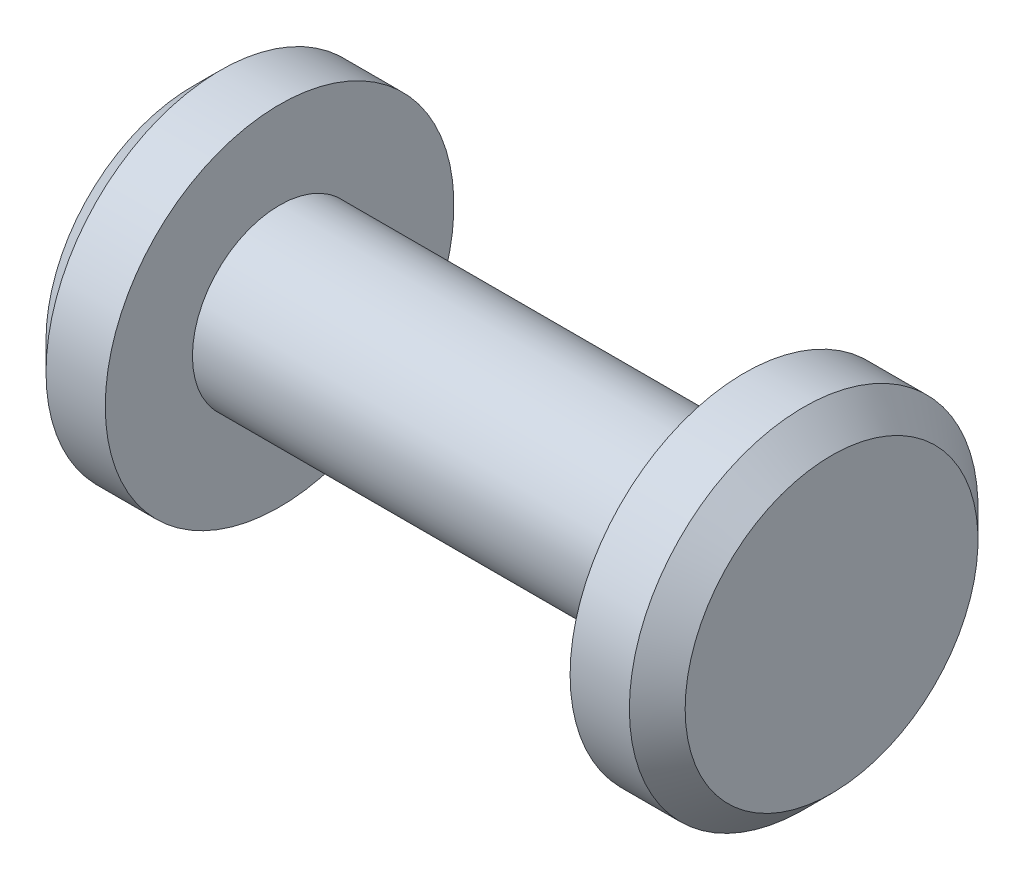
from build123d import *

# Parameters (mm, degrees)
CHAMFER1_SIZE = 0.762


with BuildPart() as part:
    # Sketch1 → Base-Revolve (revolve)
    with BuildSketch(Plane.XY):
        Polygon((8.73125, 0), (8.73125, 4.7625), (6.35, 4.7625), (6.35, 2.38125), (-6.35, 2.38125), (-6.35, 4.7625), (-8.73125, 4.7625), (-8.73125, 0), align=None)
    revolve(axis=Axis((0, 0, 0), (1, 0, 0)))

    # Chamfer1
    chamfer1_edges = [part.edges().sort_by_distance(p)[0] for p in [
        (8.73125, -4.7625, 0),
        (-8.73125, -4.7625, 0),
    ]]
    chamfer(chamfer1_edges, length=CHAMFER1_SIZE)


solid = part.part
